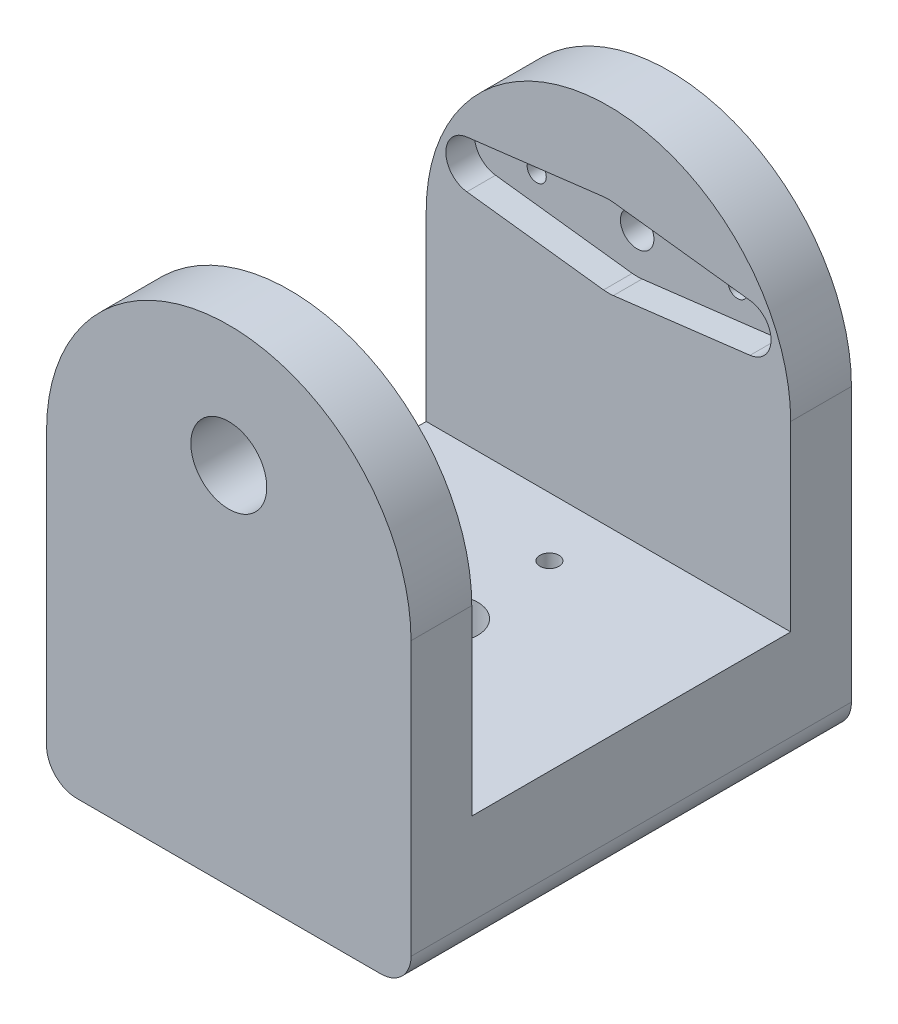
from build123d import *

# Parameters (mm, degrees)
BOSS_EXTRUDE1_DEPTH = 46.0375
FILLET1_R           = 3.175
CUT_EXTRUDE1_DEPTH  = 16.66875
SKETCH3_R           = 0.999998
SKETCH3_R_2         = 1.75
CUT_EXTRUDE2_DEPTH  = 6.35
SKETCH4_R           = 3.96875
CUT_EXTRUDE3_DEPTH  = 6.35
CUT_EXTRUDE4_DEPTH  = 3
SKETCH6_R           = 1.75
SKETCH6_R_2         = 1
CUT_EXTRUDE5_DEPTH  = 9.7
SKETCH7_R           = 3
CUT_EXTRUDE6_DEPTH  = 6.35
SKETCH9_R           = 0.999998
SKETCH9_R_2         = 1.75
CUT_EXTRUDE7_DEPTH  = 3


with BuildPart() as part:
    # Sketch1 → Boss-Extrude1 (new body)
    with BuildSketch(Plane.XY):
        with BuildLine():
            Line((0, 0), (38.1, 0))
            Line((38.1, 0), (38.1, 31.75))
            ThreePointArc((38.1, 31.75), (19.05, 50.8), (0, 31.75))
            Line((0, 31.75), (0, 0))
        make_face()
    extrude(amount=BOSS_EXTRUDE1_DEPTH)

    # Fillet1
    fillet1_edges = [part.edges().sort_by_distance(p)[0] for p in [
        (38.1, 0, 23.01875),
        (0, 0, 23.01875),
    ]]
    fillet(fillet1_edges, radius=FILLET1_R)

    # Sketch2 → Cut-Extrude1 (cut, symmetric)
    with BuildSketch(Plane(origin=(0, 0, 23.01875), x_dir=(-1, 0, 0), z_dir=(0, 0, -1))):
        with BuildLine():
            Line((-38.1, 31.75), (-38.1, 12.7))
            Line((-38.1, 12.7), (0, 12.7))
            Line((0, 12.7), (0, 31.75))
            ThreePointArc((0, 31.75), (-19.05, 50.8), (-38.1, 31.75))
        make_face()
    extrude(amount=CUT_EXTRUDE1_DEPTH, both=True, mode=Mode.SUBTRACT)

    # Sketch3 → Cut-Extrude2 (cut)
    with BuildSketch(Plane.XY.offset(6.35)):
        with Locations((8.55, 38.1)):
            Circle(SKETCH3_R)
        with Locations((29.55, 38.1)):
            Circle(SKETCH3_R)
        with Locations((19.05, 38.1)):
            Circle(SKETCH3_R_2)
    extrude(amount=-CUT_EXTRUDE2_DEPTH, mode=Mode.SUBTRACT)

    # Sketch4 → Cut-Extrude3 (cut)
    with BuildSketch(Plane(origin=(0, 0, 39.6875), x_dir=(-1, 0, 0), z_dir=(0, 0, -1))):
        with Locations((-19.05, 38.1)):
            Circle(SKETCH4_R)
    extrude(amount=-CUT_EXTRUDE3_DEPTH, mode=Mode.SUBTRACT)

    # Sketch5 → Cut-Extrude4 (cut)
    with BuildSketch(Plane.XZ):
        with BuildLine():
            Line((23.266666152, 22.4875), (21.530391854, 8.70625))
            ThreePointArc((21.530391854, 8.70625), (19.05, 6.51875), (16.569608146, 8.70625))
            Line((16.569608146, 8.70625), (14.833333848, 22.4875))
            ThreePointArc((14.833333848, 22.4875), (14.8, 23.01875), (14.833333848, 23.55))
            Line((14.833333848, 23.55), (16.569608146, 37.33125))
            ThreePointArc((16.569608146, 37.33125), (19.05, 39.51875), (21.530391854, 37.33125))
            Line((21.530391854, 37.33125), (23.266666152, 23.55))
            ThreePointArc((23.266666152, 23.55), (23.3, 23.01875), (23.266666152, 22.4875))
        make_face()
    extrude(amount=-CUT_EXTRUDE4_DEPTH, mode=Mode.SUBTRACT)

    # Sketch6 → Cut-Extrude5 (cut)
    with BuildSketch(Plane.XZ.offset(-3)):
        with Locations((19.05, 23.01875)):
            Circle(SKETCH6_R)
        with Locations((19.05, 33.51875)):
            Circle(SKETCH6_R_2)
        with Locations((19.05, 12.51875)):
            Circle(SKETCH6_R_2)
    extrude(amount=-CUT_EXTRUDE5_DEPTH, mode=Mode.SUBTRACT)

    # Sketch7 → Cut-Extrude6 (cut)
    with BuildSketch(Plane(origin=(0, 12.7, 0), x_dir=(1, 0, 0), z_dir=(0, 1, 0))):
        with Locations((19.05, -23.01875)):
            Circle(SKETCH7_R)
    extrude(amount=-CUT_EXTRUDE6_DEPTH, mode=Mode.SUBTRACT)

    # Sketch9 → Cut-Extrude7 (cut)
    with BuildSketch(Plane.XY.offset(6.35)):
        with BuildLine():
            Line((4.248275862, 40.581725719), (18.537068966, 42.318933722))
            ThreePointArc((18.537068966, 42.318933722), (19.05, 42.35), (19.562931034, 42.318933722))
            Line((19.562931034, 42.318933722), (33.851724138, 40.581725719))
            ThreePointArc((33.851724138, 40.581725719), (36.05, 38.1), (33.851724138, 35.618274281))
            Line((33.851724138, 35.618274281), (19.562931034, 33.881066278))
            ThreePointArc((19.562931034, 33.881066278), (19.05, 33.85), (18.537068966, 33.881066278))
            Line((18.537068966, 33.881066278), (4.248275862, 35.618274281))
            ThreePointArc((4.248275862, 35.618274281), (2.05, 38.1), (4.248275862, 40.581725719))
        make_face()
        with Locations((8.55, 38.1)):
            Circle(SKETCH9_R, mode=Mode.SUBTRACT)
        with Locations((29.55, 38.1)):
            Circle(SKETCH9_R, mode=Mode.SUBTRACT)
        with Locations((19.05, 38.1)):
            Circle(SKETCH9_R_2, mode=Mode.SUBTRACT)
    extrude(amount=-CUT_EXTRUDE7_DEPTH, mode=Mode.SUBTRACT)


solid = part.part
